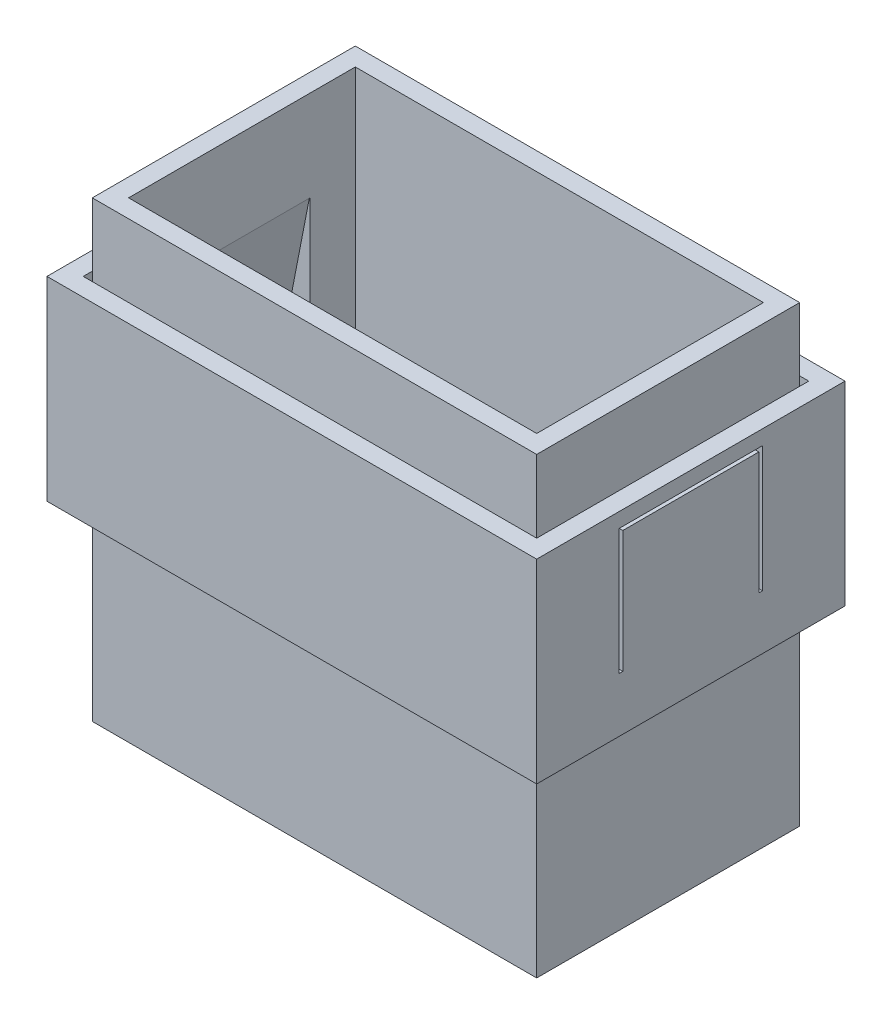
from build123d import *

# Parameters (mm, degrees)
CROQUIS1_W                 = 49
CROQUIS1_H                 = 29
CROQUIS1_W_2               = 45
CROQUIS1_H_2               = 25
SALIENTE_EXTRUIR1_DEPTH    = 25
CROQUIS2_W                 = 54
CROQUIS2_H                 = 34
CROQUIS2_W_2               = 50
CROQUIS2_H_2               = 30
SALIENTE_EXTRUIR2_DEPTH    = 17.5
CORTAR_EXTRUIR1_START      = -2
CROQUIS3_W                 = 15
CROQUIS3_H                 = 10
CORTAR_EXTRUIR1_DEPTH      = 49
SALIENTE_EXTRUIR3_REACH    = 63.904
CROQUIS4_W                 = 15
CROQUIS4_H                 = 12.818311358
CORTAR_EXTRUIR2_DEPTH      = 2
CROQUIS7_W                 = 54
CROQUIS7_H                 = 13.527722992
CORTAR_EXTRUIR3_DEPTH      = 51.0999002
CORTAR_EXTRUIR3_DEPTH_BACK = 51.0999002


with BuildPart() as part:
    # Croquis1 → Saliente-Extruir1 (new, symmetric)
    with BuildSketch(Plane(origin=(0, 0, 0), x_dir=(1, 0, 0), z_dir=(0, 1, 0))):
        Rectangle(CROQUIS1_W, CROQUIS1_H)
        Rectangle(CROQUIS1_W_2, CROQUIS1_H_2, mode=Mode.SUBTRACT)
    extrude(amount=SALIENTE_EXTRUIR1_DEPTH, both=True)

    # Croquis3 → Cortar-Extruir1 (cut)
    with BuildSketch(Plane.ZY.offset(-22.5).offset(CORTAR_EXTRUIR1_START)):
        with Locations((0, 10)):
            Rectangle(CROQUIS3_W, CROQUIS3_H)
    extrude(amount=CORTAR_EXTRUIR1_DEPTH, mode=Mode.SUBTRACT)


with BuildPart() as body_2:
    # Croquis2 → Saliente-Extruir2 (new, symmetric)
    with BuildSketch(Plane(origin=(0, 0, 0), x_dir=(1, 0, 0), z_dir=(0, 1, 0))):
        Rectangle(CROQUIS2_W, CROQUIS2_H)
        Rectangle(CROQUIS2_W_2, CROQUIS2_H_2, mode=Mode.SUBTRACT)
    extrude(amount=SALIENTE_EXTRUIR2_DEPTH, both=True)


with BuildPart() as body_3:

    # Croquis4 → Saliente-Extruir3 (new, up to next)
    with BuildSketch(Plane(origin=(24.544518702, 4.770971133, 0), x_dir=(0, 0, -1), z_dir=(0.9816271834476652, 0.19080899537653845, 0)), mode=Mode.PRIVATE) as saliente_extruir3_sk1:
        with Locations((0, 4.022049677)):
            Rectangle(CROQUIS4_W, CROQUIS4_H)
    saliente_extruir3_tool1 = extrude(saliente_extruir3_sk1.sketch, amount=SALIENTE_EXTRUIR3_REACH, mode=Mode.PRIVATE) - body_2.part
    saliente_extruir3 = saliente_extruir3_tool1.solids().sort_by_distance((23.777075, 8.719124, 0))[0]
    add(saliente_extruir3)


with BuildPart() as body_2_1:
    add(body_2.part)

    # Croquis6 → Cortar-Extruir2 (cut)
    with BuildSketch(Plane.ZY.offset(-25)):
        Polygon((-7.9, 15.885950773), (7.9, 15.885950773), (7.9, 2.027722992), (7.5, 2.027722992), (7.5, 15.485950773), (-7.5, 15.485950773), (-7.5, 2.027722992), (-7.9, 2.027722992), align=None)
    cortar_extruir2 = extrude(amount=-CORTAR_EXTRUIR2_DEPTH, mode=Mode.SUBTRACT)

    # Simetría1: Saliente-Extruir3 across plane
    add(saliente_extruir3.mirror(Plane(origin=(0, 0, 0), x_dir=(0, 0, 1), z_dir=(1, 0, 0))))

    # Simetr_a1 2: Cortar-Extruir2 across plane
    add(cortar_extruir2.mirror(Plane(origin=(0, 0, 0), x_dir=(0, 0, 1), z_dir=(1, 0, 0))), mode=Mode.SUBTRACT)

    # Croquis7 → Cortar-Extruir3 (cut, two sides)
    with BuildSketch(Plane.XY.offset(17)) as cortar_extruir3_sk:
        with Locations((0, -10.736138504)):
            Rectangle(CROQUIS7_W, CROQUIS7_H)
    extrude(amount=CORTAR_EXTRUIR3_DEPTH, mode=Mode.SUBTRACT)
    extrude(cortar_extruir3_sk.sketch, amount=-CORTAR_EXTRUIR3_DEPTH_BACK, mode=Mode.SUBTRACT)


solid = Compound([part.part, body_3.part, body_2_1.part])
